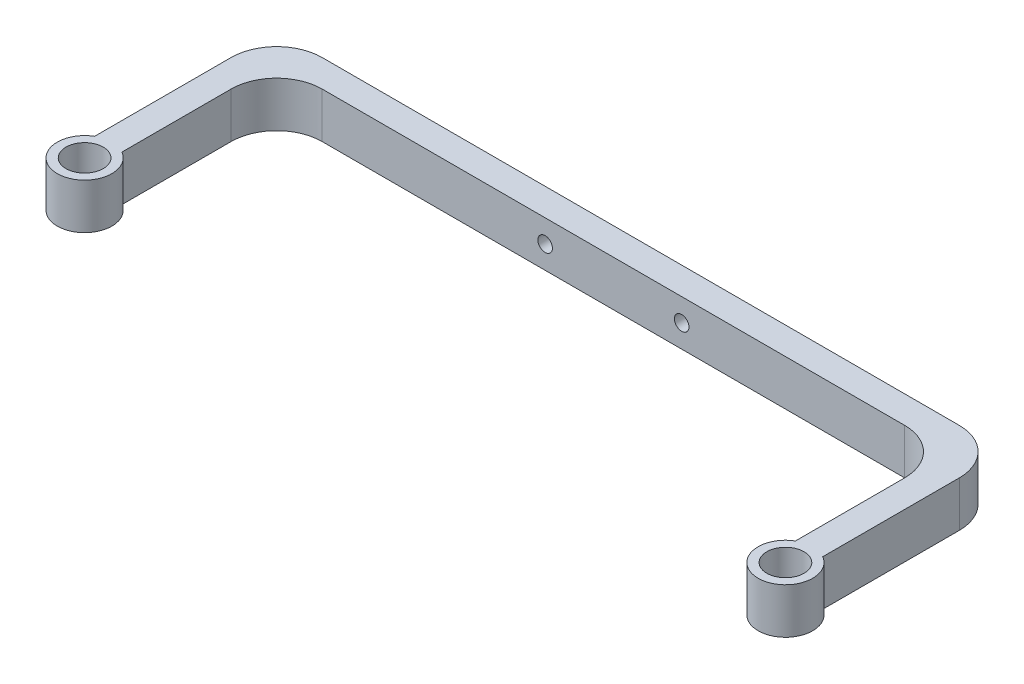
from build123d import *

# Parameters (mm, degrees)
SKETCH_1_R          = 4.1
EXTRUDE_1_DEPTH     = 10
SKETCH_3_R          = 1.6
CUT_EXTRUDE_1_DEPTH = 52.196152423
FILLET_1_R          = 10


with BuildPart() as part:
    # Эскиз1 → Бобышка-Вытянуть1 (new body)
    with BuildSketch(Plane(origin=(0, 0, 0), x_dir=(1, 0, 0), z_dir=(0, 1, 0))):
        with BuildLine():
            Line((-63.596685083, 9.903314917), (96.403314917, 9.903314917))
            Line((96.403314917, 9.903314917), (96.403314917, -30.096685083))
            ThreePointArc((96.403314917, -30.096685083), (93.403314917, -41.292837506), (90.403314917, -30.096685083))
            Line((90.403314917, -30.096685083), (90.403314917, 3.903314917))
            Line((90.403314917, 3.903314917), (-57.596685083, 3.903314917))
            Line((-57.596685083, 3.903314917), (-57.596685083, -30.096685083))
            ThreePointArc((-57.596685083, -30.096685083), (-60.596685083, -41.292837506), (-63.596685083, -30.096685083))
            Line((-63.596685083, -30.096685083), (-63.596685083, 9.903314917))
        make_face()
        with Locations((-60.596685083, -35.292837506)):
            Circle(SKETCH_1_R, mode=Mode.SUBTRACT)
        with Locations((93.403314917, -35.292837506)):
            Circle(SKETCH_1_R, mode=Mode.SUBTRACT)
    extrude(amount=EXTRUDE_1_DEPTH)

    # Эскиз3 → Вырез-Вытянуть1 (cut, through all)
    with BuildSketch(Plane(origin=(0, 0, -9.903314917), x_dir=(-1, 0, 0), z_dir=(0, 0, -1))):
        with Locations((-1.403314917, 5)):
            Circle(SKETCH_3_R)
        with Locations((-31.403314917, 5)):
            Circle(SKETCH_3_R)
    extrude(amount=-CUT_EXTRUDE_1_DEPTH, mode=Mode.SUBTRACT)

    # Скругление1
    fillet_1_edges = [part.edges().sort_by_distance(p)[0] for p in [
        (-63.596685083, 5, -9.903314917),
        (96.403314917, 5, -9.903314917),
        (90.403314917, 5, -3.903314917),
        (-57.596685083, 5, -3.903314917),
    ]]
    fillet(fillet_1_edges, radius=FILLET_1_R)


solid = part.part
